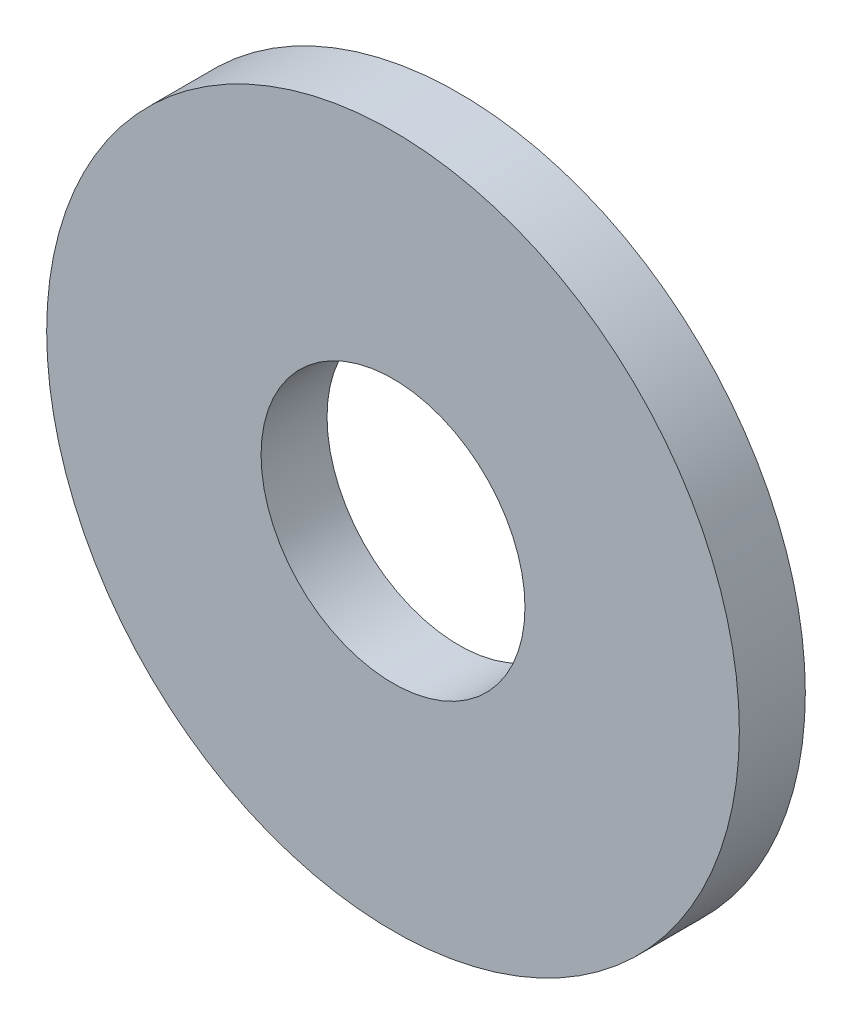
from build123d import *

# Parameters (mm, degrees)
SKETCH1_R           = 10.5
SKETCH1_R_2         = 4
BOSS_EXTRUDE1_DEPTH = 2


with BuildPart() as part:
    # Sketch1 → Boss-Extrude1 (new body)
    with BuildSketch(Plane.XY):
        Circle(SKETCH1_R)
        Circle(SKETCH1_R_2, mode=Mode.SUBTRACT)
    extrude(amount=BOSS_EXTRUDE1_DEPTH)


solid = part.part
